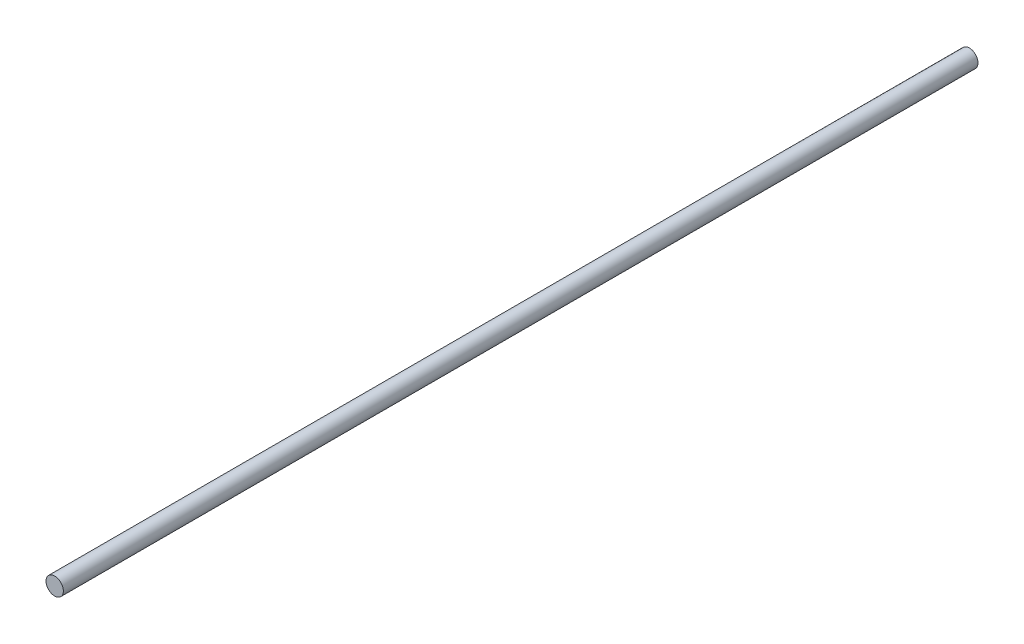
from build123d import *

# Parameters (mm, degrees)
SKETCH1_R           = 2.375
BOSS_EXTRUDE1_DEPTH = 250


with BuildPart() as part:
    # Sketch1 → Boss-Extrude1 (new body)
    with BuildSketch(Plane.XY):
        Circle(SKETCH1_R)
    extrude(amount=BOSS_EXTRUDE1_DEPTH)


solid = part.part
